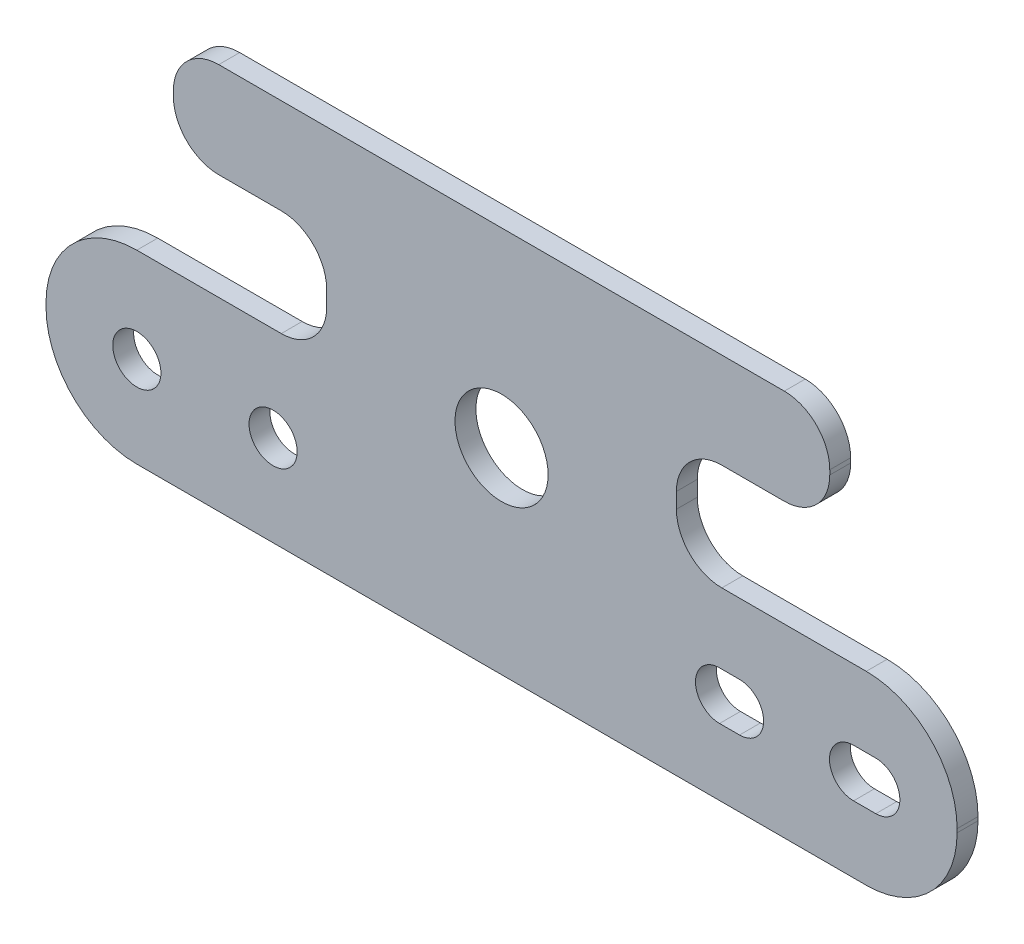
from build123d import *

# Parameters (mm, degrees)
BOSS_EXTRUDE1_DEPTH = 2.3
CUT_EXTRUDE1_REACH  = 4.3
SKETCH2_R           = 2.65
SKETCH2_R_2         = 5.125


with BuildPart() as part:
    # Sketch1 → Boss-Extrude1 (new body)
    with BuildSketch(Plane.XY):
        with BuildLine():
            Line((40.15, 0), (-40.15, 0))
            ThreePointArc((-40.15, 0), (-47.221067812, 2.928932188), (-50.15, 10))
            Line((-50.15, 10), (-50.15, 10.4))
            ThreePointArc((-50.15, 10.4), (-47.221067812, 17.471067812), (-40.15, 20.4))
            Line((-40.15, 20.4), (-24.25, 20.4))
            ThreePointArc((-24.25, 20.4), (-20.714466094, 21.864466094), (-19.25, 25.4))
            Line((-19.25, 25.4), (-19.25, 27.1))
            ThreePointArc((-19.25, 27.1), (-20.714466094, 30.635533906), (-24.25, 32.1))
            Line((-24.25, 32.1), (-31.13, 32.1))
            ThreePointArc((-31.13, 32.1), (-34.665533906, 33.564466094), (-36.13, 37.1))
            Line((-36.13, 37.1), (-36.13, 37.6))
            ThreePointArc((-36.13, 37.6), (-34.665533906, 41.135533906), (-31.13, 42.6))
            Line((-31.13, 42.6), (31.13, 42.6))
            ThreePointArc((31.13, 42.6), (34.665533906, 41.135533906), (36.13, 37.6))
            Line((36.13, 37.6), (36.13, 37.1))
            ThreePointArc((36.13, 37.1), (34.665533906, 33.564466094), (31.13, 32.1))
            Line((31.13, 32.1), (24.25, 32.1))
            ThreePointArc((24.25, 32.1), (20.714466094, 30.635533906), (19.25, 27.1))
            Line((19.25, 27.1), (19.25, 25.4))
            ThreePointArc((19.25, 25.4), (20.714466094, 21.864466094), (24.25, 20.4))
            Line((24.25, 20.4), (40.15, 20.4))
            ThreePointArc((40.15, 20.4), (47.221067812, 17.471067812), (50.15, 10.4))
            Line((50.15, 10.4), (50.15, 10))
            ThreePointArc((50.15, 10), (47.221067812, 2.928932188), (40.15, 0))
        make_face()
    extrude(amount=BOSS_EXTRUDE1_DEPTH)

    # Sketch2 → Cut-Extrude1 (cut, up to next)
    with BuildSketch(Plane.XY.offset(2.3), mode=Mode.PRIVATE) as cut_extrude1_sk1:
        with Locations((-40.150797604, 10)):
            Circle(SKETCH2_R)
    cut_extrude1_tool1 = extrude(cut_extrude1_sk1.sketch, amount=-CUT_EXTRUDE1_REACH, mode=Mode.PRIVATE) & part.part
    add(cut_extrude1_tool1.solids().sort_by_distance((-40.150798, 10, 2.3))[0], mode=Mode.SUBTRACT)
    # Sketch2 → Cut-Extrude1 (cut, up to next)
    with BuildSketch(Plane.XY.offset(2.3), mode=Mode.PRIVATE) as cut_extrude1_sk2:
        with Locations((-25.150797604, 10)):
            Circle(SKETCH2_R)
    cut_extrude1_tool2 = extrude(cut_extrude1_sk2.sketch, amount=-CUT_EXTRUDE1_REACH, mode=Mode.PRIVATE) & part.part
    add(cut_extrude1_tool2.solids().sort_by_distance((-25.150798, 10, 2.3))[0], mode=Mode.SUBTRACT)
    # Sketch2 → Cut-Extrude1 (cut, up to next)
    with BuildSketch(Plane.XY.offset(2.3), mode=Mode.PRIVATE) as cut_extrude1_sk3:
        with Locations((0, 21.625)):
            Circle(SKETCH2_R_2)
    cut_extrude1_tool3 = extrude(cut_extrude1_sk3.sketch, amount=-CUT_EXTRUDE1_REACH, mode=Mode.PRIVATE) & part.part
    add(cut_extrude1_tool3.solids().sort_by_distance((0, 21.625, 2.3))[0], mode=Mode.SUBTRACT)
    # Sketch2 → Cut-Extrude1 (cut, up to next)
    with BuildSketch(Plane.XY.offset(2.3), mode=Mode.PRIVATE) as cut_extrude1_sk4:
        with BuildLine():
            Line((23.999202396, 12.65), (26.199202396, 12.65))
            ThreePointArc((26.199202396, 12.65), (28.849202396, 10), (26.199202396, 7.35))
            Line((26.199202396, 7.35), (23.999202396, 7.35))
            ThreePointArc((23.999202396, 7.35), (21.349202396, 10), (23.999202396, 12.65))
        make_face()
    cut_extrude1_tool4 = extrude(cut_extrude1_sk4.sketch, amount=-CUT_EXTRUDE1_REACH, mode=Mode.PRIVATE) & part.part
    add(cut_extrude1_tool4.solids().sort_by_distance((25.099202, 10, 2.3))[0], mode=Mode.SUBTRACT)
    # Sketch2 → Cut-Extrude1 (cut, up to next)
    with BuildSketch(Plane.XY.offset(2.3), mode=Mode.PRIVATE) as cut_extrude1_sk5:
        with BuildLine():
            Line((38.749202396, 12.65), (41.199202396, 12.65))
            ThreePointArc((41.199202396, 12.65), (43.849202396, 10), (41.199202396, 7.35))
            Line((41.199202396, 7.35), (38.749202396, 7.35))
            ThreePointArc((38.749202396, 7.35), (36.099202396, 10), (38.749202396, 12.65))
        make_face()
    cut_extrude1_tool5 = extrude(cut_extrude1_sk5.sketch, amount=-CUT_EXTRUDE1_REACH, mode=Mode.PRIVATE) & part.part
    add(cut_extrude1_tool5.solids().sort_by_distance((39.974202, 10, 2.3))[0], mode=Mode.SUBTRACT)


solid = part.part
